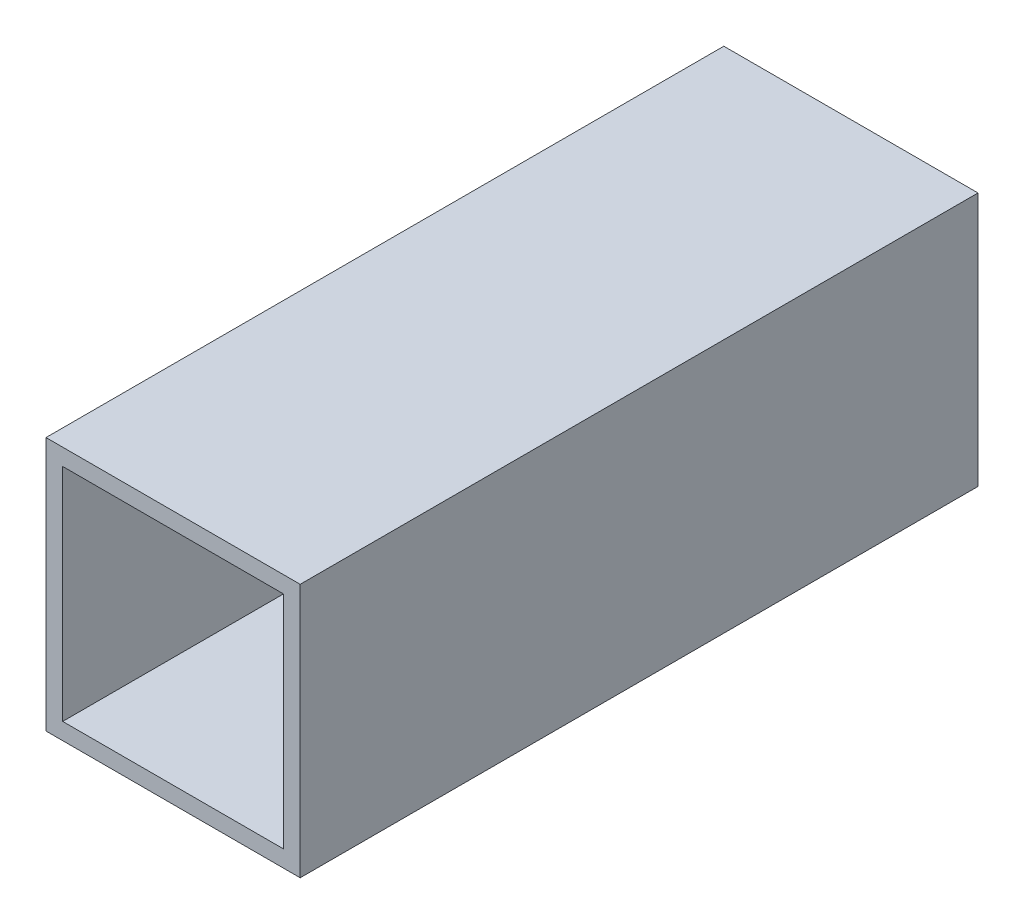
from build123d import *

# Parameters (mm, degrees)
SKETCH1_W           = 76.2
SKETCH1_H           = 76.2
SKETCH1_W_2         = 66.2
SKETCH1_H_2         = 66.2
BOSS_EXTRUDE1_DEPTH = 203.2


with BuildPart() as part:
    # Sketch1 → Boss-Extrude1 (new body)
    with BuildSketch(Plane.XY):
        Rectangle(SKETCH1_W, SKETCH1_H)
        Rectangle(SKETCH1_W_2, SKETCH1_H_2, mode=Mode.SUBTRACT)
    extrude(amount=BOSS_EXTRUDE1_DEPTH)


solid = part.part
